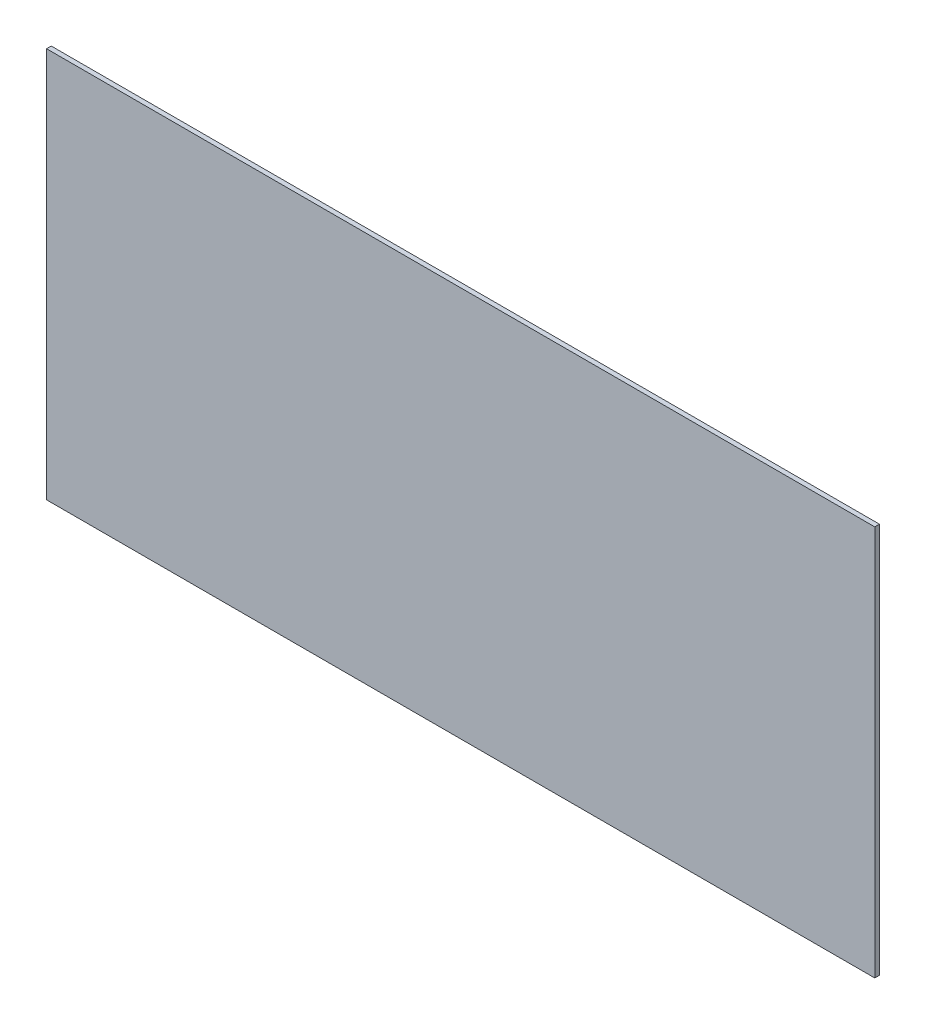
from build123d import *

# Parameters (mm, degrees)
ESBO_O1_W                = 530
ESBO_O1_H                = 250
RESSALTO_EXTRUS_O1_DEPTH = 3


with BuildPart() as part:
    # Esboço1 → Ressalto-extrusão1 (new body)
    with BuildSketch(Plane.XY):
        Rectangle(ESBO_O1_W, ESBO_O1_H)
    extrude(amount=RESSALTO_EXTRUS_O1_DEPTH)


solid = part.part
